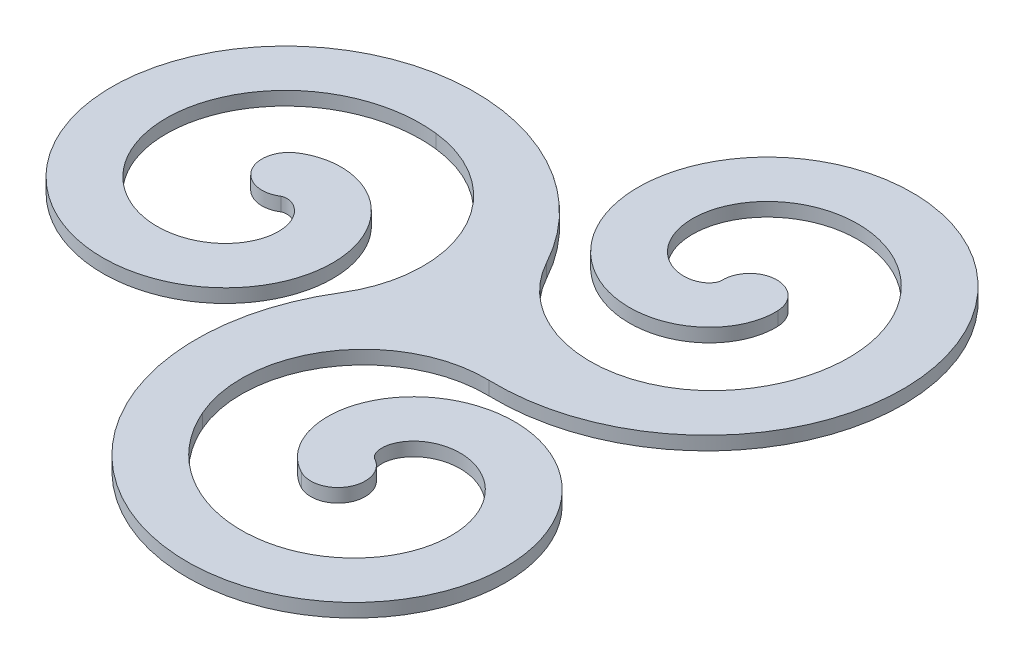
from build123d import *

# Parameters (mm, degrees)
AUFSATZ_LINEAR_AUSTRAGEN1_DEPTH = 10
KREISMUSTER1_COUNT              = 3
VERRUNDUNG1_R                   = 90


with BuildPart() as part:
    # Skizze2 → Aufsatz-Linear austragen1 (new body)
    with BuildSketch(Plane(origin=(0, 0, 0), x_dir=(1, 0, 0), z_dir=(0, 1, 0))):
        with BuildLine():
            ThreePointArc((35.740585443, 8.128727839), (8.128727839, 14.259414557), (14.259414557, 41.871272161))
            add(Edge.make_bspline(
                [(14.259414557, 41.871272161), (16.187475942, 43.098714161), (20.216135423, 45.236658399), (29.067285828, 48.316371346), (41.165101816, 49.650290701), (56.208424096, 46.885016637), (70.533721678, 39.679693038), (82.910072025, 28.286847425), (92.183389312, 13.279543253), (97.364932507, -4.465793444), (97.709830263, -23.814038366), (92.785186033, -43.437439288), (82.519461639, -61.900350558), (67.228655244, -77.756845773), (47.615853075, -89.654618334), (24.742835887, -96.437763087), (-0.02557886, -97.240867022), (-25.101728865, -91.567177681), (-48.775213975, -79.344496344), (-69.326683453, -60.953798485), (-85.147849045, -37.227337405), (-94.85953934, -9.415025374), (-97.41943455, 20.879924205), (-92.211525172, 51.792918547), (-79.11031164, 81.312253953), (-58.514251684, 107.408768322), (-31.344886362, 128.172589737), (0.989710673, 141.94791135), (36.666062592, 147.456480048), (73.547718377, 143.901089653), (109.312638487, 131.040777038), (141.600326788, 109.233423632), (163.733886393, 84.40108778), (177.594101698, 61.306009339), (185.86067287, 42.615591874), (190.824753811, 26.112210225), (193.566367511, 12.510023084), (194.520305669, 5.579075951), (194.88836263, 2.110220815)],
                knots=[0, 0, 0, 0, 0.015625, 0.03125, 0.0625, 0.09375, 0.125, 0.15625, 0.1875, 0.21875, 0.25, 0.28125, 0.3125, 0.34375, 0.375, 0.40625, 0.4375, 0.46875, 0.5, 0.53125, 0.5625, 0.59375, 0.625, 0.65625, 0.6875, 0.71875, 0.75, 0.78125, 0.8125, 0.84375, 0.875, 0.90625, 0.9375, 0.953125, 0.96875, 0.984375, 0.9921875, 1, 1, 1, 1], degree=3))
            ThreePointArc((194.88836263, 2.110220815), (177.110220815, -19.88836263), (155.11163737, -2.110220815))
            add(Edge.make_bspline(
                [(35.740585443, 8.128727839), (35.815948013, 8.176705141), (35.953359037, 8.257073162), (36.381015155, 8.466286752), (37.07106093, 8.713973214), (38.215959628, 8.934578713), (40.114571678, 9.013061178), (43.128834596, 8.511383141), (47.346087123, 6.452609971), (51.574870074, 2.628029358), (55.134643322, -3.045837987), (57.329117234, -10.411441585), (57.52243346, -19.075806052), (55.21039378, -28.437264856), (50.081392177, -37.731423876), (42.062186879, -46.093138369), (31.344547696, -52.629937868), (18.390121642, -56.501332311), (3.91243163, -56.997813169), (-11.163362367, -53.613202202), (-25.760589136, -46.10431584), (-38.727133116, -34.53269314), (-48.922150661, -19.284331447), (-55.30715426, -1.064907202), (-57.034631388, 19.130275206), (-53.527301976, 40.070489879), (-44.541562186, 60.364986057), (-30.209591902, 78.554922756), (-11.055969468, 93.21578526), (12.013665115, 103.063231412), (37.752372998, 107.054749513), (64.63869535, 104.479652975), (90.966447733, 95.02994994), (114.953915347, 78.847675665), (131.541586358, 60.256609215), (141.98827757, 42.854257316), (148.243592414, 28.715948105), (152.014790697, 16.183214207), (154.102560909, 5.827012521), (154.830854558, 0.536094841), (155.11163737, -2.110220815)],
                knots=[0, 0, 0, 0, 0.0078125, 0.015625, 0.03125, 0.046875, 0.0625, 0.09375, 0.125, 0.15625, 0.1875, 0.21875, 0.25, 0.28125, 0.3125, 0.34375, 0.375, 0.40625, 0.4375, 0.46875, 0.5, 0.53125, 0.5625, 0.59375, 0.625, 0.65625, 0.6875, 0.71875, 0.75, 0.78125, 0.8125, 0.84375, 0.875, 0.90625, 0.9375, 0.953125, 0.96875, 0.984375, 0.9921875, 1, 1, 1, 1], degree=3))
        make_face()
    extrude(amount=AUFSATZ_LINEAR_AUSTRAGEN1_DEPTH)


with BuildPart() as kreismuster1_1:
    # Kreismuster1: pattern copy
    add(part.part.rotate(Axis((175, 10.5, 0), (0, -1, 0)), 1 * 360 / KREISMUSTER1_COUNT))


with BuildPart() as kreismuster1_2:
    # Kreismuster1: pattern copy
    add(part.part.rotate(Axis((175, 10.5, 0), (0, -1, 0)), 2 * 360 / KREISMUSTER1_COUNT))


with BuildPart() as part_1:
    add(part.part)

    # Kombinieren1: union Kreismuster1_1, Kreismuster1_2
    add(kreismuster1_1.part)
    add(kreismuster1_2.part)

    # Verrundung1
    verrundung1_edges = [part_1.edges().sort_by_distance(p)[0] for p in [
        (193.139355341, 5, -14.321779748),
        (178.333347419, 5, 22.870032408),
        (153.52729724, 5, -8.54825266),
    ]]
    fillet(verrundung1_edges, radius=VERRUNDUNG1_R)


solid = part_1.part
